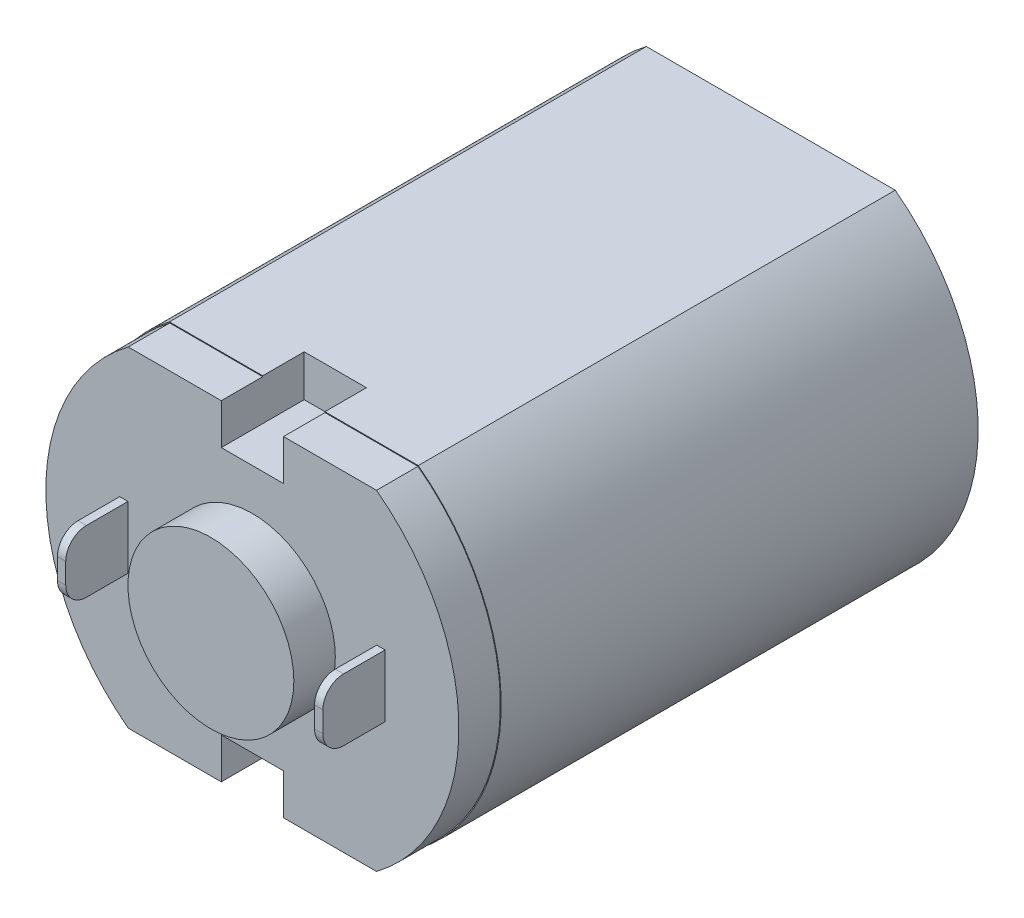
from build123d import *

# Parameters (mm, degrees)
BOSS_EXTRUDE1_DEPTH = 12.5
SKETCH2_R           = 2
SKETCH2_R_2         = 0.5
BOSS_EXTRUDE2_DEPTH = 0.5
SKETCH2_2_R         = 0.5
BOSS_EXTRUDE3_DEPTH = 3
SKETCH2_4_R         = 2
BOSS_EXTRUDE4_DEPTH = 13.5
CUT_EXTRUDE1_START  = 12.5
SKETCH4_W           = 1.5
SKETCH4_H           = 2
CUT_EXTRUDE1_DEPTH  = 2
BOSS_EXTRUDE5_START = 12.5
SKETCH5_W           = 0.2
SKETCH5_H           = 1.5
BOSS_EXTRUDE5_DEPTH = 1.5
FILLET1_R           = 0.5
CUT_EXTRUDE2_START  = 12.5
CUT_EXTRUDE2_DEPTH  = 1


with BuildPart() as part:
    # Sketch1 → Boss-Extrude1 (new body)
    with BuildSketch(Plane.XY):
        with BuildLine():
            Line((-3, -4), (3, -4))
            ThreePointArc((3, -4), (5, 0), (3, 4))
            Line((3, 4), (-3, 4))
            ThreePointArc((-3, 4), (-5, 0), (-3, -4))
        make_face()
    extrude(amount=BOSS_EXTRUDE1_DEPTH)

    # Sketch2 → Boss-Extrude2 (add)
    with BuildSketch(Plane.XY):
        Circle(SKETCH2_R)
        Circle(SKETCH2_R_2, mode=Mode.SUBTRACT)
    extrude(amount=-BOSS_EXTRUDE2_DEPTH)

    # Sketch2_2 → Boss-Extrude3 (add)
    with BuildSketch(Plane.XY):
        Circle(SKETCH2_2_R)
    extrude(amount=-BOSS_EXTRUDE3_DEPTH)

    # Sketch2_4 → Boss-Extrude4 (add)
    with BuildSketch(Plane.XY):
        Circle(SKETCH2_4_R)
    extrude(amount=BOSS_EXTRUDE4_DEPTH)

    # Sketch4 → Cut-Extrude1 (cut)
    with BuildSketch(Plane.XY.offset(CUT_EXTRUDE1_START)):
        with Locations((0, 4)):
            Rectangle(SKETCH4_W, SKETCH4_H)
        with Locations((0, -4)):
            Rectangle(SKETCH4_W, SKETCH4_H)
    extrude(amount=-CUT_EXTRUDE1_DEPTH, mode=Mode.SUBTRACT)

    # Sketch5 → Boss-Extrude5 (add)
    with BuildSketch(Plane.XY.offset(BOSS_EXTRUDE5_START)):
        with Locations((3.1, 0)):
            Rectangle(SKETCH5_W, SKETCH5_H)
        with Locations((-3.1, 0)):
            Rectangle(SKETCH5_W, SKETCH5_H)
    extrude(amount=BOSS_EXTRUDE5_DEPTH)

    # Fillet1
    fillet1_edges = [part.edges().sort_by_distance(p)[0] for p in [
        (3.1, -0.75, 14),
        (3.1, 0.75, 14),
        (-3.1, -0.75, 14),
        (-3.1, 0.75, 14),
    ]]
    fillet(fillet1_edges, radius=FILLET1_R)

    # Sketch6 → Cut-Extrude2 (cut)
    with BuildSketch(Plane.XY.offset(CUT_EXTRUDE2_START)):
        with BuildLine():
            Line((-3, -4), (3, -4))
            ThreePointArc((3, -4), (5, 0), (3, 4))
            Line((3, 4), (-3, 4))
            ThreePointArc((-3, 4), (-5, 0), (-3, -4))
        make_face()
        with BuildLine():
            Line((-2.993325909, -3.98), (2.993325909, -3.98))
            ThreePointArc((2.993325909, -3.98), (4.98, 0), (2.993325909, 3.98))
            Line((2.993325909, 3.98), (-2.993325909, 3.98))
            ThreePointArc((-2.993325909, 3.98), (-4.98, 0), (-2.993325909, -3.98))
        make_face(mode=Mode.SUBTRACT)
    extrude(amount=-CUT_EXTRUDE2_DEPTH, mode=Mode.SUBTRACT)


solid = part.part
